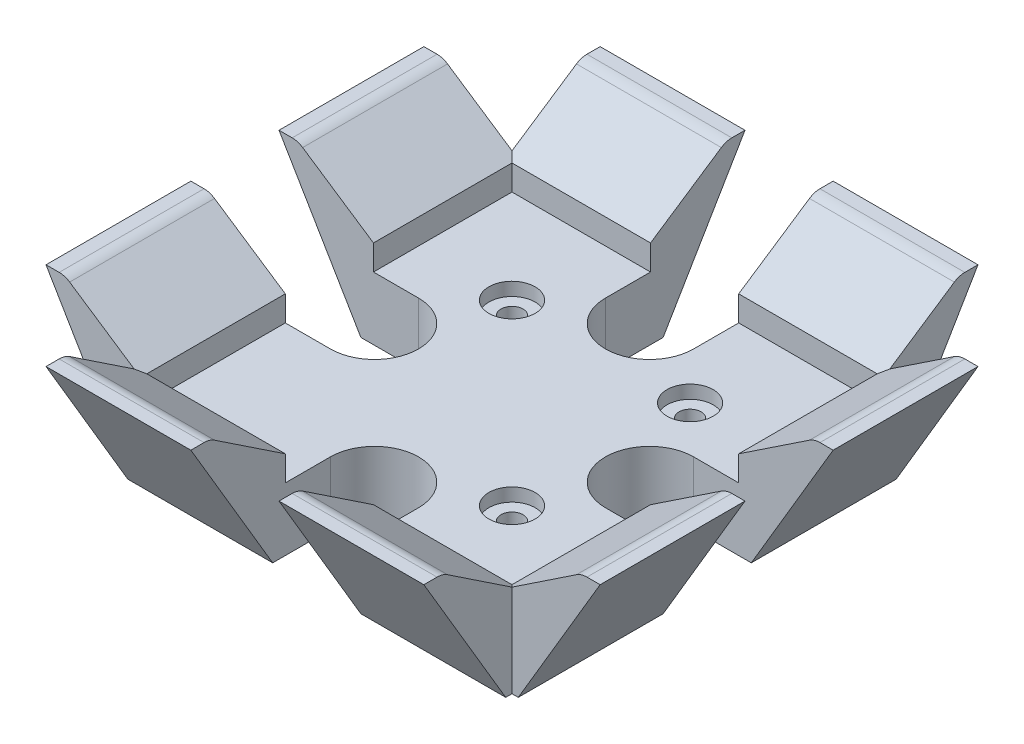
from build123d import *

# Parameters (mm, degrees)
SKETCH1_W               = 58
SKETCH1_H               = 58
BOSS_EXTRUDE1_DEPTH     = 10
BOSS_EXTRUDE3_DEPTH     = 30.005
CIRPATTERN7_COUNT       = 4
CUT_EXTRUDE1_DEPTH      = 13
CUT_EXTRUDE1_DEPTH_BACK = 11
SKETCH8_R               = 1.75
CUT_EXTRUDE2_DEPTH      = 20
SKETCH9_R               = 3.665
CUT_EXTRUDE3_DEPTH      = 2.1


with BuildPart() as part:
    # Sketch1 → Boss-Extrude1 (new body)
    with BuildSketch(Plane(origin=(0, 0, 0), x_dir=(1, 0, 0), z_dir=(0, 1, 0))):
        Rectangle(SKETCH1_W, SKETCH1_H)
    extrude(amount=BOSS_EXTRUDE1_DEPTH)

    # Sketch2 → Boss-Extrude3 (add, symmetric)
    with BuildSketch(Plane.XY):
        with BuildLine():
            Line((29, 0), (29, 14))
            Line((29, 14), (40.244226325, 21.496150883))
            ThreePointArc((40.244226325, 21.496150883), (41.038974467, 21.871276079), (41.908326913, 22))
            Line((41.908326913, 22), (44, 22))
            Line((44, 22), (31, 0))
            Line((31, 0), (29, 0))
        make_face()
    boss_extrude3 = extrude(amount=BOSS_EXTRUDE3_DEPTH, both=True)

    # CirPattern7: Boss-Extrude3 ×4 about axis
    cirpattern7_axis = Axis((0, 0, 0), (0, 1, 0))
    for i in range(1, CIRPATTERN7_COUNT):
        add(boss_extrude3.rotate(cirpattern7_axis, i * 360 / CIRPATTERN7_COUNT))

    # Sketch7 → Cut-Extrude1 (cut, two sides)
    with BuildSketch(Plane(origin=(0, 10, 0), x_dir=(1, 0, 0), z_dir=(0, 1, 0))) as cut_extrude1_sk:
        with BuildLine():
            Line((21.84, 7), (54.527297937, 7))
            Line((54.527297937, 7), (54.527297937, -7))
            Line((54.527297937, -7), (21.84, -7))
            ThreePointArc((21.84, -7), (14.84, 0), (21.84, 7))
        make_face()
        with BuildLine():
            Line((7, -21.84), (7, -54.527297937))
            Line((7, -54.527297937), (-7, -54.527297937))
            Line((-7, -54.527297937), (-7, -21.84))
            ThreePointArc((-7, -21.84), (0, -14.84), (7, -21.84))
        make_face()
        with BuildLine():
            Line((-21.84, -7), (-54.527297937, -7))
            Line((-54.527297937, -7), (-54.527297937, 7))
            Line((-54.527297937, 7), (-21.84, 7))
            ThreePointArc((-21.84, 7), (-14.84, 0), (-21.84, -7))
        make_face()
        with BuildLine():
            Line((-7, 21.84), (-7, 54.527297937))
            Line((-7, 54.527297937), (7, 54.527297937))
            Line((7, 54.527297937), (7, 21.84))
            ThreePointArc((7, 21.84), (0, 14.84), (-7, 21.84))
        make_face()
    extrude(amount=CUT_EXTRUDE1_DEPTH, mode=Mode.SUBTRACT)
    extrude(cut_extrude1_sk.sketch, amount=-CUT_EXTRUDE1_DEPTH_BACK, mode=Mode.SUBTRACT)

    # Sketch8 → Cut-Extrude2 (cut)
    with BuildSketch(Plane(origin=(-225.294025085, 10, 60.777514946), x_dir=(0, 0, -1), z_dir=(0, 1, 0))):
        with Locations((74.91965057, -211.151889461)):
            Circle(SKETCH8_R)
        with Locations((74.91965057, -239.436160708)):
            Circle(SKETCH8_R)
        with Locations((46.635379323, -239.436160708)):
            Circle(SKETCH8_R)
    extrude(amount=-CUT_EXTRUDE2_DEPTH, mode=Mode.SUBTRACT)

    # Sketch9 → Cut-Extrude3 (cut)
    with BuildSketch(Plane(origin=(0, 10, 0), x_dir=(1, 0, 0), z_dir=(0, 1, 0))):
        with Locations((-14.142135624, 14.142135624)):
            Circle(SKETCH9_R)
        with Locations((14.142135624, -14.142135624)):
            Circle(SKETCH9_R)
        with Locations((14.142135624, 14.142135624)):
            Circle(SKETCH9_R)
    extrude(amount=-CUT_EXTRUDE3_DEPTH, mode=Mode.SUBTRACT)


solid = part.part
